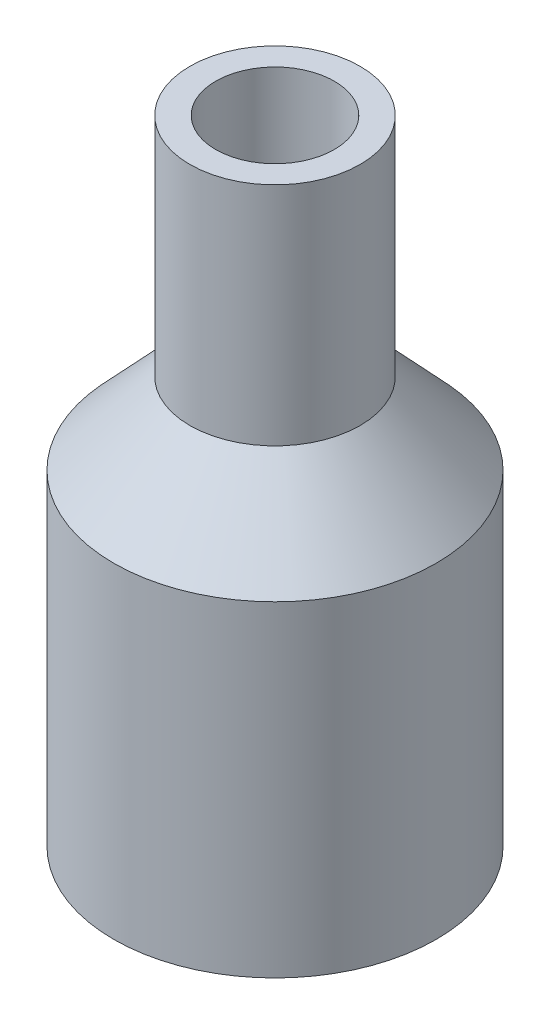
from build123d import *


with BuildPart() as part:
    # Esquisse1 → Révolution1 (revolve)
    with BuildSketch(Plane.XY):
        Polygon((0, 0), (0, 53.316037736), (12.462876168, 66.594634639), (12.462876168, 103.597786518), (16.687075107, 103.597786518), (16.687075107, 65.817397653), (3.717899157, 51.999362612), (3.717899157, 0), align=None)
    revolve(axis=Axis((26.389502741, 105.802883707, 0), (0, -1, 0)))


solid = part.part
